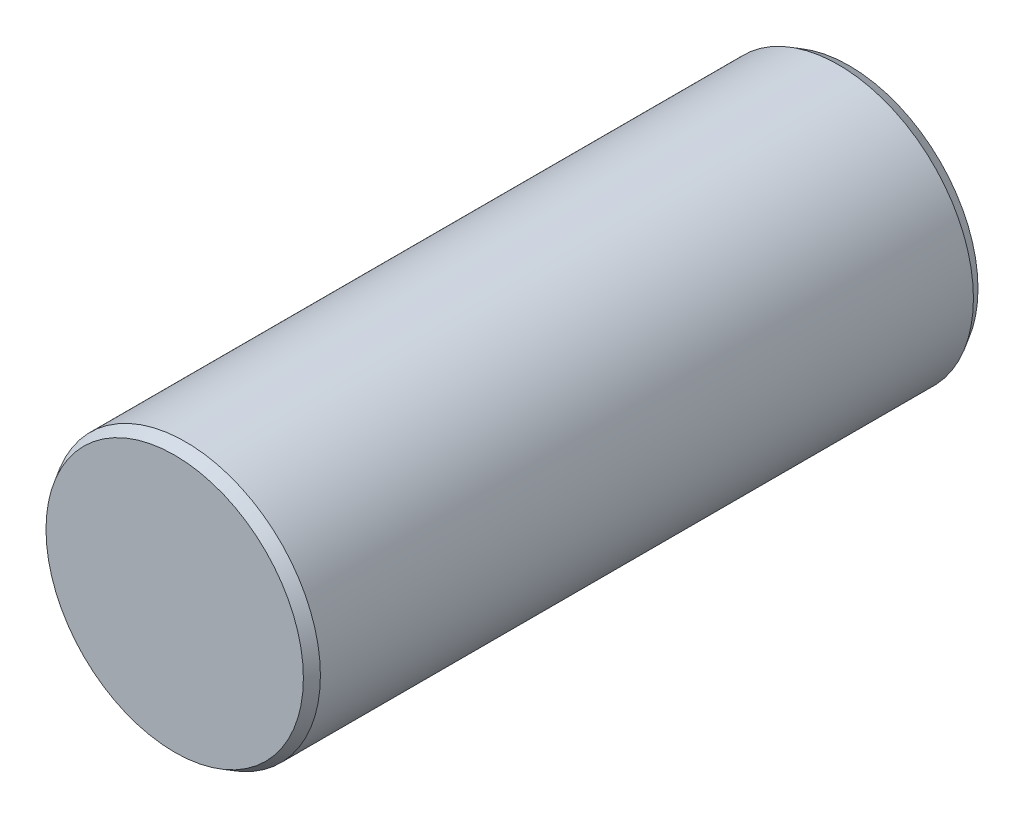
from build123d import *

# Parameters (mm, degrees)
ESQUISSE1_R        = 2.5
BOSS_EXTRU_1_DEPTH = 6.25
CHANFREIN1_SIZE    = 0.2
CHANFREIN1_SIZE2   = 0.115470054


with BuildPart() as part:
    # Esquisse1 → Boss.-Extru.1 (new body, symmetric)
    with BuildSketch(Plane.XY):
        Circle(ESQUISSE1_R)
    extrude(amount=BOSS_EXTRU_1_DEPTH, both=True)

    # Chanfrein1
    chanfrein1_edges = [part.edges().sort_by_distance(p)[0] for p in [
        (-2.5, 0, -6.25),
        (-2.5, 0, 6.25),
    ]]
    chanfrein1_side = [part.faces().sort_by_distance(p)[0] for p in [
        (-2.5, 0, 0),
    ]]
    chamfer(chanfrein1_edges, length=CHANFREIN1_SIZE, length2=CHANFREIN1_SIZE2, reference=chanfrein1_side[0])


solid = part.part
